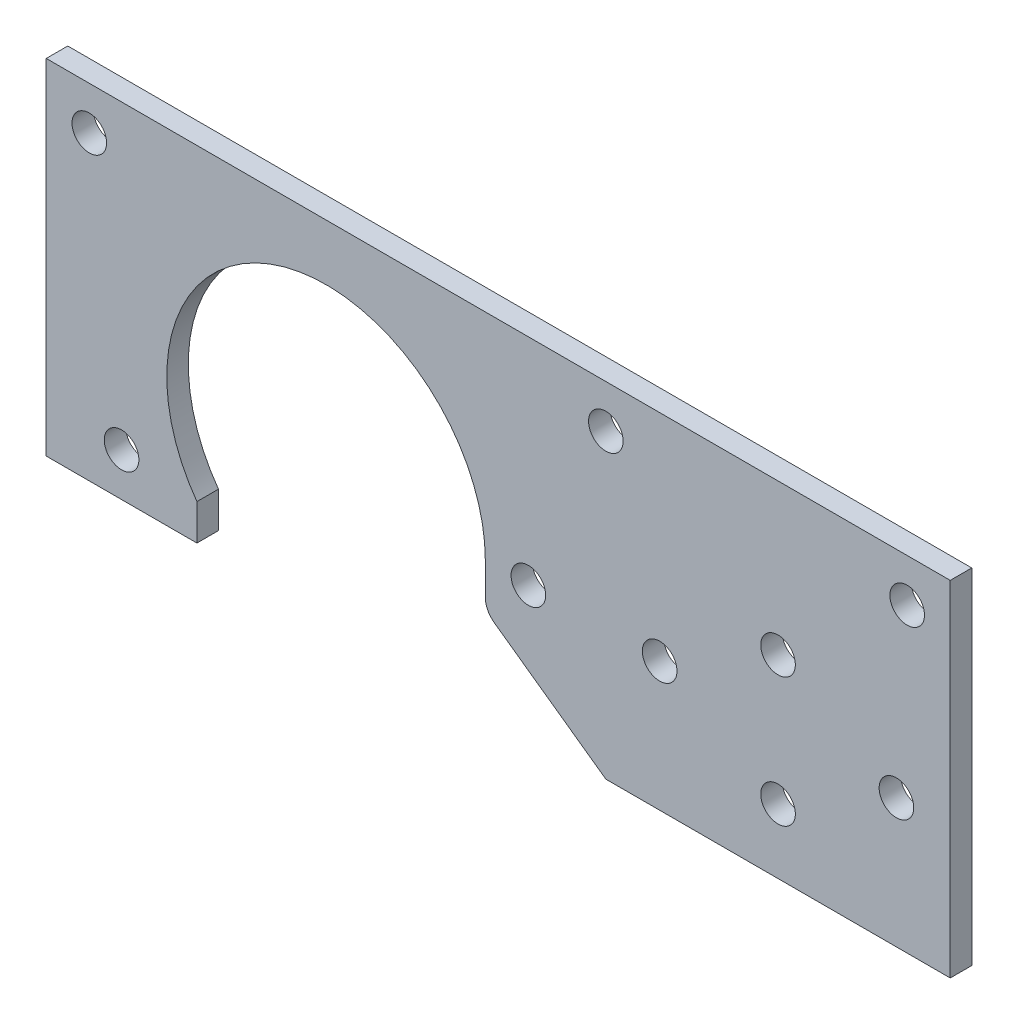
from build123d import *

# Parameters (mm, degrees)
SKETCH1_R           = 2.5527
BOSS_EXTRUDE1_DEPTH = 3.175
SKETCH3_R           = 2.5527
CUT_EXTRUDE2_DEPTH  = 143.733819135
FILLET1_R           = 3.175


with BuildPart() as part:
    # Sketch1 → Boss-Extrude1 (new body)
    with BuildSketch(Plane.XY):
        with BuildLine():
            Line((0, 0), (0, 50.8))
            Line((0, 50.8), (-133.35, 50.8))
            Line((-133.35, 50.8), (-133.35, 0))
            Line((-133.35, 0), (-111.125, 0))
            Line((-111.125, 0), (-111.125, 5.298181029))
            ThreePointArc((-111.125, 5.298181029), (-99.30117724, 41.406148763), (-68.58, 19.05))
            Line((-68.58, 19.05), (-68.58, 12.7))
            Line((-68.58, 12.7), (-50.8, 0))
            Line((-50.8, 0), (0, 0))
        make_face()
        with Locations((-25.4, 9.525)):
            Circle(SKETCH1_R, mode=Mode.SUBTRACT)
        with Locations((-25.4, 28.575)):
            Circle(SKETCH1_R, mode=Mode.SUBTRACT)
        with Locations((-7.9375, 19.05)):
            Circle(SKETCH1_R, mode=Mode.SUBTRACT)
        with Locations((-42.8625, 19.05)):
            Circle(SKETCH1_R, mode=Mode.SUBTRACT)
    extrude(amount=BOSS_EXTRUDE1_DEPTH)

    # Sketch3 → Cut-Extrude2 (cut, through all)
    with BuildSketch(Plane(origin=(0, 0, 0), x_dir=(-1, 0, 0), z_dir=(0, 0, -1))):
        with Locations((122.2375, 6.35)):
            Circle(SKETCH3_R)
        with Locations((127, 44.45)):
            Circle(SKETCH3_R)
        with Locations((6.35, 44.45)):
            Circle(SKETCH3_R)
        with Locations((50.8, 44.45)):
            Circle(SKETCH3_R)
        with Locations((62.23, 19.05)):
            Circle(SKETCH3_R)
    extrude(amount=-CUT_EXTRUDE2_DEPTH, mode=Mode.SUBTRACT)

    # Fillet1
    fillet1_edges = [part.edges().sort_by_distance(p)[0] for p in [
        (-68.58, 12.7, 1.5875),
    ]]
    fillet(fillet1_edges, radius=FILLET1_R)


solid = part.part
